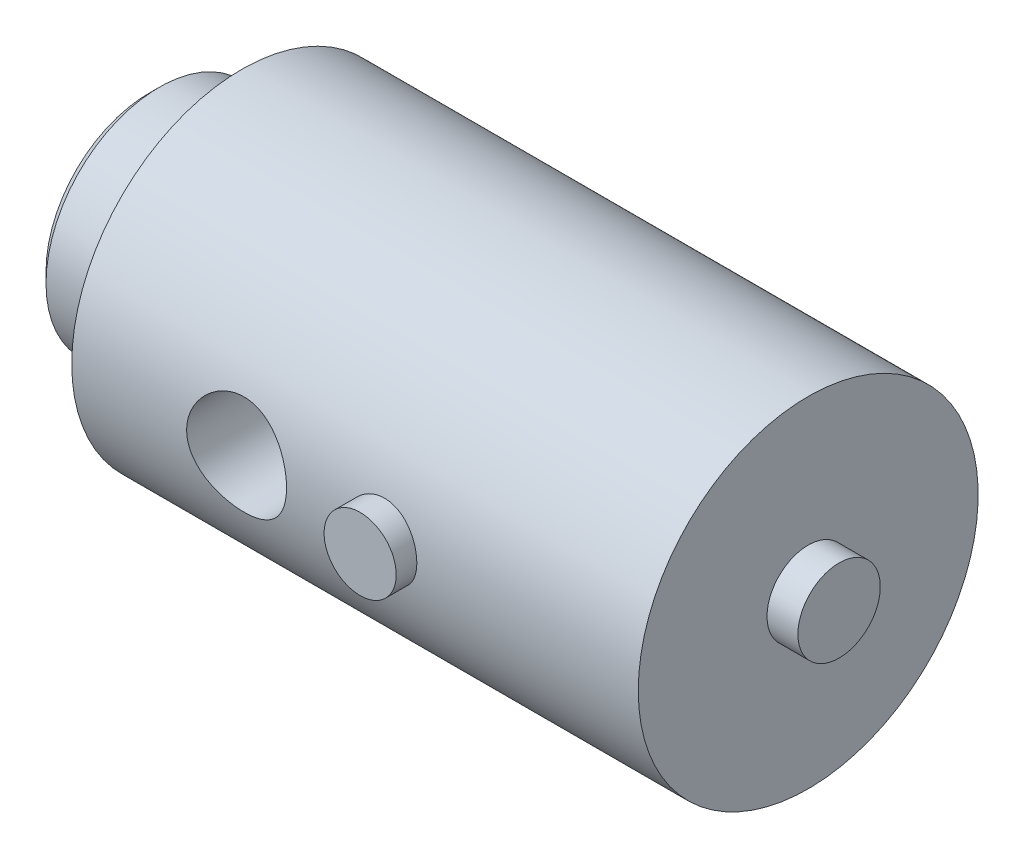
from build123d import *

# Parameters (mm, degrees)
SKETCH2_R                            = 4.85
CUT_EXTRUDE1_DEPTH                   = 9
SKETCH3_R                            = 3.5
BOSS_EXTRUDE1_DEPTH                  = 2
BOSS_EXTRUDE1_DIRECTION_2_REACH      = 78.487
BOSS_EXTRUDE1_DIRECTION_2_END_RADIUS = 16.5


with BuildPart() as part:
    # Sketch1 → Revolve1 (revolve)
    with BuildSketch(Plane(origin=(0, 0, 0), x_dir=(1, 0, 0), z_dir=(0, 1, 0)), mode=Mode.PRIVATE) as revolve1_sk:
        Polygon((0, 10), (0, 6), (2, 4), (11, 4), (11, 0), (67, 0), (67, 4), (64, 4), (64, 16.5), (9, 16.5), (9, 11), (1, 11), align=None)
    revolve(revolve1_sk.sketch.rotate(Axis((0, 0, 0), (1, 0, 0)), 180), axis=Axis((0, 0, 0), (1, 0, 0)))

    # Sketch2 → Cut-Extrude1 (cut)
    with BuildSketch(Plane.XY.offset(16.5)):
        with Locations((25, 0)):
            Circle(SKETCH2_R)
    extrude(amount=-CUT_EXTRUDE1_DEPTH, mode=Mode.SUBTRACT)


with BuildPart() as boss_extrude1_tool:
    # Sketch3 → Boss-Extrude1 (new body)
    with BuildSketch(Plane.XY.offset(16.5)):
        with Locations((39, 0)):
            Circle(SKETCH3_R)
    extrude(amount=BOSS_EXTRUDE1_DEPTH)


with BuildPart() as part_1:
    add(part.part)


with BuildPart() as part_2:
    # Boss-Extrude1: joined with boss_extrude1_tool
    add(part_1.part.fuse(boss_extrude1_tool.part, tol=0.00001))

    # Boss-Extrude1 direction 2: up to this cylinder (the profile starts outside it)
    boss_extrude1_direction_2_end = Plane(origin=(39, 0, 0), z_dir=(-1, 0, 0)) * Cylinder(BOSS_EXTRUDE1_DIRECTION_2_END_RADIUS, 190.974, mode=Mode.PRIVATE)
    # Sketch3 → Boss-Extrude1 direction 2 (add, up to the surface)
    with BuildSketch(Plane.XY.offset(16.5), mode=Mode.PRIVATE) as boss_extrude1_direction_2_sk1:
        with Locations((39, 0)):
            Circle(SKETCH3_R)
    boss_extrude1_direction_2_tool1 = extrude(boss_extrude1_direction_2_sk1.sketch, amount=-BOSS_EXTRUDE1_DIRECTION_2_REACH, mode=Mode.PRIVATE) - boss_extrude1_direction_2_end
    add(boss_extrude1_direction_2_tool1.solids().sort_by_distance((39, 0, 16.5))[0])
    add(boss_extrude1_direction_2_tool1.solids().sort_by_distance((39, 0, 16.5))[1])


solid = part_2.part
